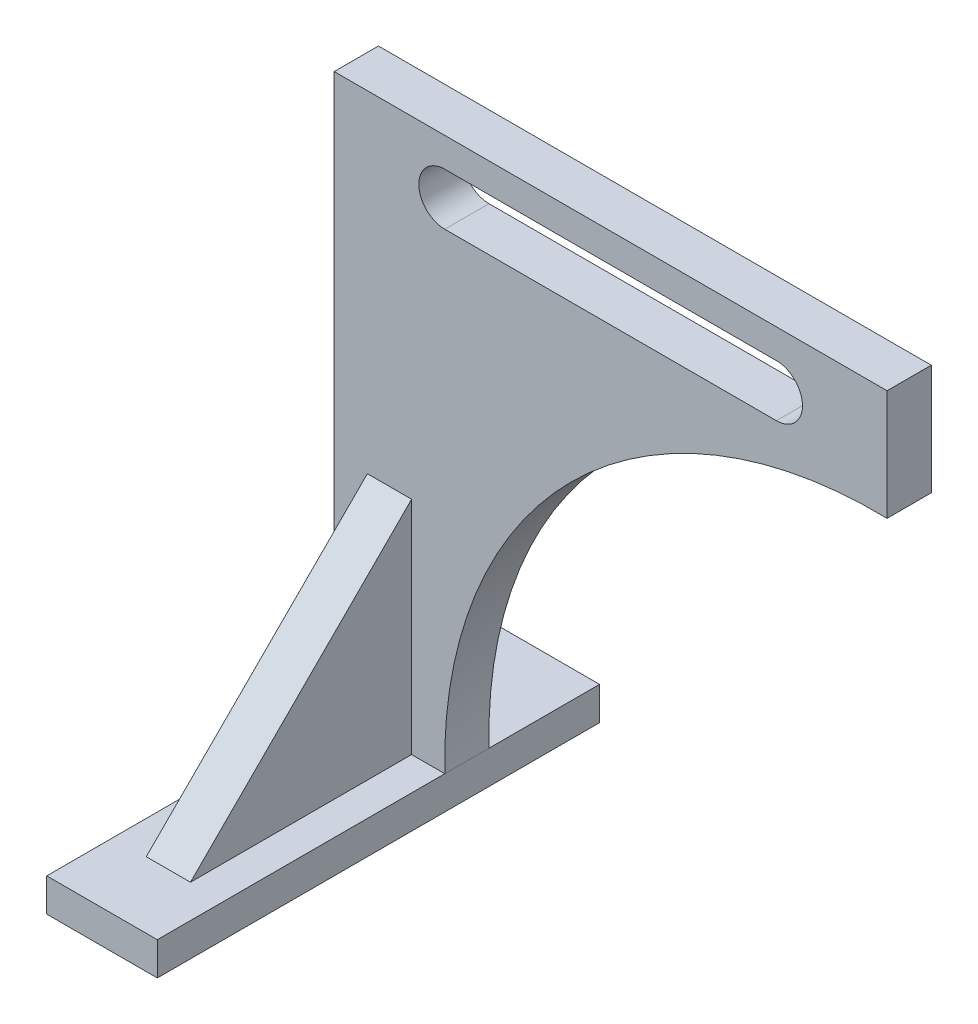
from build123d import *

# Parameters (mm, degrees)
SKETCH1_W           = 50
SKETCH1_H           = 200
BOSS_EXTRUDE1_DEPTH = 15
BOSS_EXTRUDE2_DEPTH = 20
BOSS_EXTRUDE3_DEPTH = 10
CUT_EXTRUDE1_DEPTH  = 71


with BuildPart() as part:
    # Sketch1 → Boss-Extrude1 (new body)
    with BuildSketch(Plane(origin=(0, 0, 0), x_dir=(1, 0, 0), z_dir=(0, 1, 0))):
        Rectangle(SKETCH1_W, SKETCH1_H)
    extrude(amount=BOSS_EXTRUDE1_DEPTH)

    # Sketch2 → Boss-Extrude2 (add)
    with BuildSketch(Plane.XY.offset(-50)):
        with BuildLine():
            Line((-25, 15), (-25, 265))
            Line((-25, 265), (225, 265))
            Line((225, 265), (225, 215))
            ThreePointArc((225, 215), (82.144079422, 157.855920578), (25, 15))
            Line((25, 15), (-25, 15))
        make_face()
    extrude(amount=BOSS_EXTRUDE2_DEPTH)

    # Sketch3 → Boss-Extrude3 (add, symmetric)
    with BuildSketch(Plane(origin=(0, 0, 0), x_dir=(0, 0, -1), z_dir=(1, 0, 0))):
        Polygon((-70, 15), (30, 15), (30, 115), align=None)
    extrude(amount=BOSS_EXTRUDE3_DEPTH, both=True)

    # Sketch4 → Cut-Extrude1 (cut, through all)
    with BuildSketch(Plane.XY.offset(-30)):
        with BuildLine():
            Line((25, 228.25), (175, 228.25))
            ThreePointArc((175, 228.25), (186.75, 240), (175, 251.75))
            Line((175, 251.75), (25, 251.75))
            ThreePointArc((25, 251.75), (13.25, 240), (25, 228.25))
        make_face()
    extrude(amount=-CUT_EXTRUDE1_DEPTH, mode=Mode.SUBTRACT)


solid = part.part
